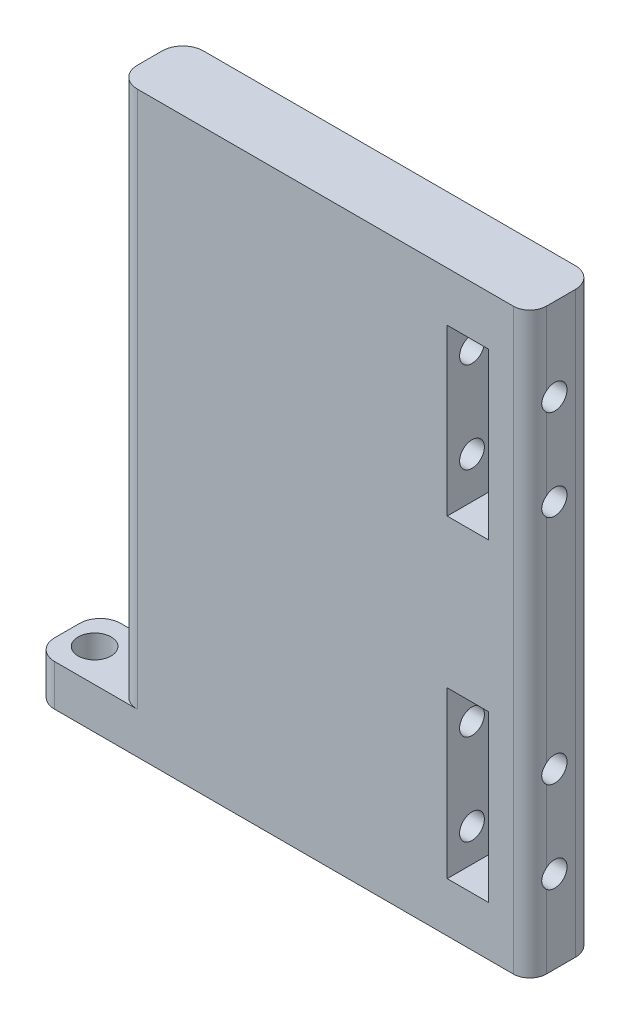
from build123d import *

# Parameters (mm, degrees)
ESBO_O2_W                = 50
ESBO_O2_H                = 70
RESSALTO_EXTRUS_O1_DEPTH = 8
ESBO_O3_R                = 0.75
CORTE_EXTRUS_O1_DEPTH    = 30
FILETE1_R                = 2
ESBO_O17_W               = 10
ESBO_O17_H               = 5
RESSALTO_EXTRUS_O4_DEPTH = 8
ESBO_O20_R               = 2
CORTE_EXTRUS_O9_DEPTH    = 8
FILETE2_R                = 2.5
FILETE3_R                = 2.5
FILETE4_R                = 2.5
FILETE5_R                = 2.5
ESBO_O21_W               = 5
ESBO_O21_H               = 20
CORTE_EXTRUS_O10_DEPTH   = 9
FILETE6_R                = 2.5
ESBO_O22_R               = 1.5
CORTE_EXTRUS_O11_DEPTH   = 20


with BuildPart() as part:
    # Esboço2 → Ressalto-extrusão1 (new body)
    with BuildSketch(Plane.XY):
        with Locations((-42.281248797, -0.107598663)):
            Rectangle(ESBO_O2_W, ESBO_O2_H)
    extrude(amount=RESSALTO_EXTRUS_O1_DEPTH)

    # Esboço3 → Corte-extrusão1 (cut)
    with BuildSketch(Plane(origin=(0, -35.107598663, 0), x_dir=(-1, 0, 0), z_dir=(0, -1, 0))):
        with Locations((58.281248797, -4)):
            Circle(ESBO_O3_R)
        with Locations((63.281248797, -4)):
            Circle(ESBO_O3_R)
    extrude(amount=-CORTE_EXTRUS_O1_DEPTH, mode=Mode.SUBTRACT)

    # Filete1
    filete1_edges = [part.edges().sort_by_distance(p)[0] for p in [
        (-17.281248797, -0.107598663, 8),
    ]]
    fillet(filete1_edges, radius=FILETE1_R)

    # Esboço17 → Ressalto-extrusão4 (add)
    with BuildSketch(Plane(origin=(0, 0, 0), x_dir=(-1, 0, 0), z_dir=(0, 0, -1))):
        with Locations((72.281248797, -32.607598663)):
            Rectangle(ESBO_O17_W, ESBO_O17_H)
    extrude(amount=-RESSALTO_EXTRUS_O4_DEPTH)

    # Esboço20 → Corte-extrusão9 (cut)
    with BuildSketch(Plane.XZ.offset(35.107598663)):
        with Locations((-73.951248797, 4)):
            Circle(ESBO_O20_R)
    extrude(amount=-CORTE_EXTRUS_O9_DEPTH, mode=Mode.SUBTRACT)

    # Filete2
    filete2_edges = [part.edges().sort_by_distance(p)[0] for p in [
        (-67.281248797, 2.392401337, 8),
    ]]
    fillet(filete2_edges, radius=FILETE2_R)

    # Filete3
    filete3_edges = [part.edges().sort_by_distance(p)[0] for p in [
        (-67.281248797, 2.392401337, 0),
    ]]
    fillet(filete3_edges, radius=FILETE3_R)

    # Filete4
    filete4_edges = [part.edges().sort_by_distance(p)[0] for p in [
        (-77.281248797, -32.607598663, 8),
    ]]
    fillet(filete4_edges, radius=FILETE4_R)

    # Filete5
    filete5_edges = [part.edges().sort_by_distance(p)[0] for p in [
        (-77.281248797, -32.607598663, 0),
    ]]
    fillet(filete5_edges, radius=FILETE5_R)

    # Esboço21 → Corte-extrusão10 (cut, through all)
    with BuildSketch(Plane.XY.offset(8)):
        with Locations((-24.781248797, 18.892401337)):
            Rectangle(ESBO_O21_W, ESBO_O21_H)
        with Locations((-24.781248797, -19.107598663)):
            Rectangle(ESBO_O21_W, ESBO_O21_H)
    extrude(amount=-CORTE_EXTRUS_O10_DEPTH, mode=Mode.SUBTRACT)

    # Filete6
    filete6_edges = [part.edges().sort_by_distance(p)[0] for p in [
        (-17.281248797, -0.107598663, 0),
    ]]
    fillet(filete6_edges, radius=FILETE6_R)

    # Esboço22 → Corte-extrusão11 (cut)
    with BuildSketch(Plane(origin=(-17.281248797, 0, 0), x_dir=(0, 0, -1), z_dir=(1, 0, 0))):
        with Locations((-5, -25.107598663)):
            Circle(ESBO_O22_R)
        with Locations((-5, -14.107598663)):
            Circle(ESBO_O22_R)
        with Locations((-5, 24.892401337)):
            Circle(ESBO_O22_R)
        with Locations((-5, 13.892401337)):
            Circle(ESBO_O22_R)
    extrude(amount=-CORTE_EXTRUS_O11_DEPTH, mode=Mode.SUBTRACT)


solid = part.part
